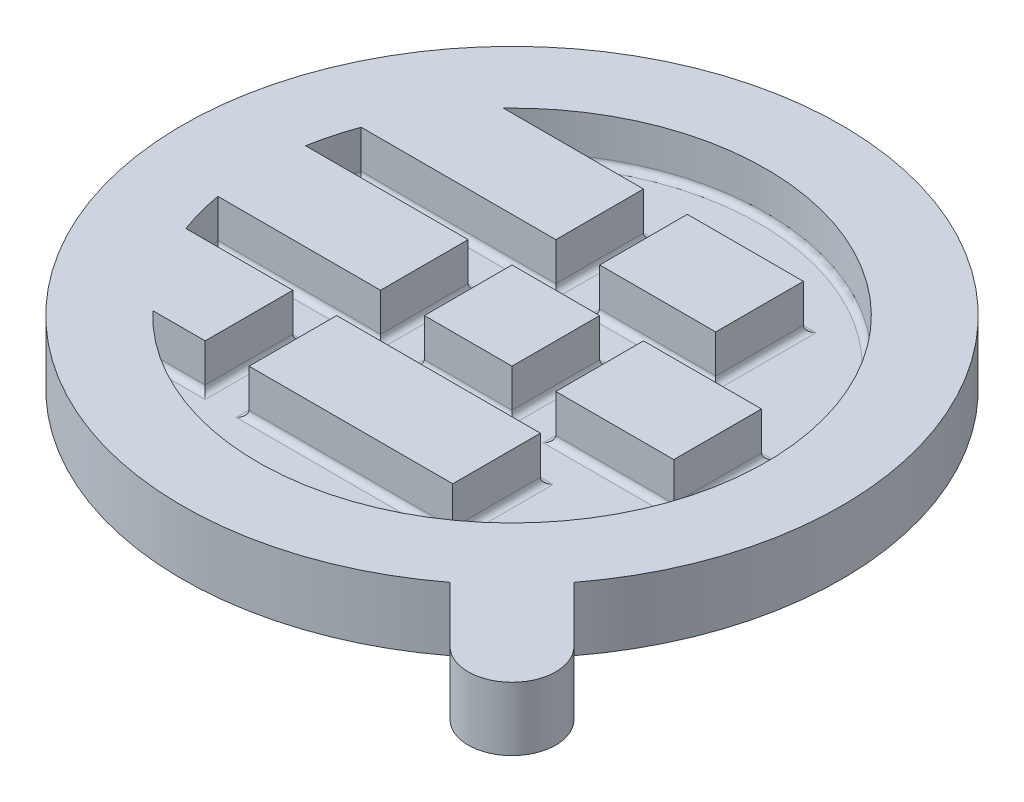
from build123d import *

# Parameters (mm, degrees)
BOSS_EXTRUDE12_DEPTH = 3
SKETCH1_16_W         = 18.27
SKETCH1_16_H         = 13.8
SKETCH1_16_W_2       = 18.57
SKETCH1_16_W_3       = 32.07
BOSS_EXTRUDE13_DEPTH = 10
SKETCH1_17_W         = 13.8
SKETCH1_17_H         = 13.8
BOSS_EXTRUDE14_DEPTH = 10
FILLET1_R            = 1


with BuildPart() as part:
    # Sketch1 → Boss-Extrude12 (new body)
    with BuildSketch(Plane(origin=(0, 0, 0), x_dir=(1, 0, 0), z_dir=(0, 1, 0))):
        with BuildLine():
            Line((81.494030169, 8.747896251), (90.24192642, 0))
            ThreePointArc((90.24192642, 0), (100, 0), (100, 9.75807358))
            Line((100, 9.75807358), (91.252103749, 18.505969831))
            ThreePointArc((91.252103749, 18.505969831), (13.301158056, 86.698841944), (81.494030169, 8.747896251))
        make_face()
    extrude(amount=BOSS_EXTRUDE12_DEPTH)

    # Sketch1_16 → Boss-Extrude13 (add)
    # profile 1 of 4: a face of its own
    with BuildSketch(Plane(origin=(0, 0, 0), x_dir=(1, 0, 0), z_dir=(0, 1, 0))):
        with BuildLine():
            Line((81.494030169, 8.747896251), (90.24192642, 0))
            ThreePointArc((90.24192642, 0), (100, 0), (100, 9.75807358))
            Line((100, 9.75807358), (91.252103749, 18.505969831))
            ThreePointArc((91.252103749, 18.505969831), (13.301158056, 86.698841944), (81.494030169, 8.747896251))
        make_face()
        with BuildLine():
            Line((21.047625313, 22.4), (29.3, 22.4))
            Line((29.3, 22.4), (29.3, 36.2))
            Line((29.3, 36.2), (12.455892606, 36.2))
            ThreePointArc((12.455892606, 36.2), (11.37337625, 39.608467983), (10.599619291, 43.1))
            Line((10.599619291, 43.1), (36.2, 43.1))
            Line((36.2, 43.1), (36.2, 56.9))
            Line((36.2, 56.9), (10.599619291, 56.9))
            ThreePointArc((10.599619291, 56.9), (11.37337625, 60.391532017), (12.455892606, 63.8))
            Line((12.455892606, 63.8), (43.1, 63.8))
            Line((43.1, 63.8), (43.1, 77.6))
            Line((43.1, 77.6), (21.047625313, 77.6))
            ThreePointArc((21.047625313, 77.6), (90, 50), (21.047625313, 22.4))
        make_face(mode=Mode.SUBTRACT)
    # profile 2 of 4: a face of its own
    with BuildSketch(Plane(origin=(0, 0, 0), x_dir=(1, 0, 0), z_dir=(0, 1, 0))):
        with Locations((59.135, 70.7)):
            Rectangle(SKETCH1_16_W, SKETCH1_16_H)
    # profile 3 of 4: a face of its own
    with BuildSketch(Plane(origin=(0, 0, 0), x_dir=(1, 0, 0), z_dir=(0, 1, 0))):
        with Locations((73.085, 50)):
            Rectangle(SKETCH1_16_W_2, SKETCH1_16_H)
    # profile 4 of 4: a face of its own
    with BuildSketch(Plane(origin=(0, 0, 0), x_dir=(1, 0, 0), z_dir=(0, 1, 0))):
        with Locations((52.235, 29.3)):
            Rectangle(SKETCH1_16_W_3, SKETCH1_16_H)
    extrude(amount=BOSS_EXTRUDE13_DEPTH)

    # Sketch1_17 → Boss-Extrude14 (add)
    with BuildSketch(Plane(origin=(0, 0, 0), x_dir=(1, 0, 0), z_dir=(0, 1, 0))):
        with Locations((50, 50)):
            Rectangle(SKETCH1_17_W, SKETCH1_17_H)
    extrude(amount=BOSS_EXTRUDE14_DEPTH)

    # Fillet1
    fillet1_edges = [part.edges().sort_by_distance(p)[0] for p in [
        (90, 3, -50),
        (36.2, 3, -29.3),
        (52.235, 3, -22.4),
        (50, 3, -70.7),
        (59.135, 3, -63.8),
        (43.1, 3, -50),
        (50, 3, -43.1),
        (63.8, 3, -50),
        (73.085, 3, -43.1),
        (50, 3, -56.9),
        (73.085, 3, -56.9),
        (56.9, 3, -50),
        (52.235, 3, -36.2),
        (68.27, 3, -29.3),
        (82.37, 3, -50),
        (68.27, 3, -70.7),
        (59.135, 3, -77.6),
        (32.073812657, 3, -77.6),
        (43.1, 3, -70.7),
        (27.777946303, 3, -63.8),
        (11.37337625, 3, -60.391532017),
        (23.399809646, 3, -56.9),
        (36.2, 3, -50),
        (23.399809646, 3, -43.1),
        (11.37337625, 3, -39.608467983),
        (20.877946303, 3, -36.2),
        (29.3, 3, -29.3),
        (25.173812657, 3, -22.4),
    ]]
    fillet(fillet1_edges, radius=FILLET1_R)


solid = part.part
